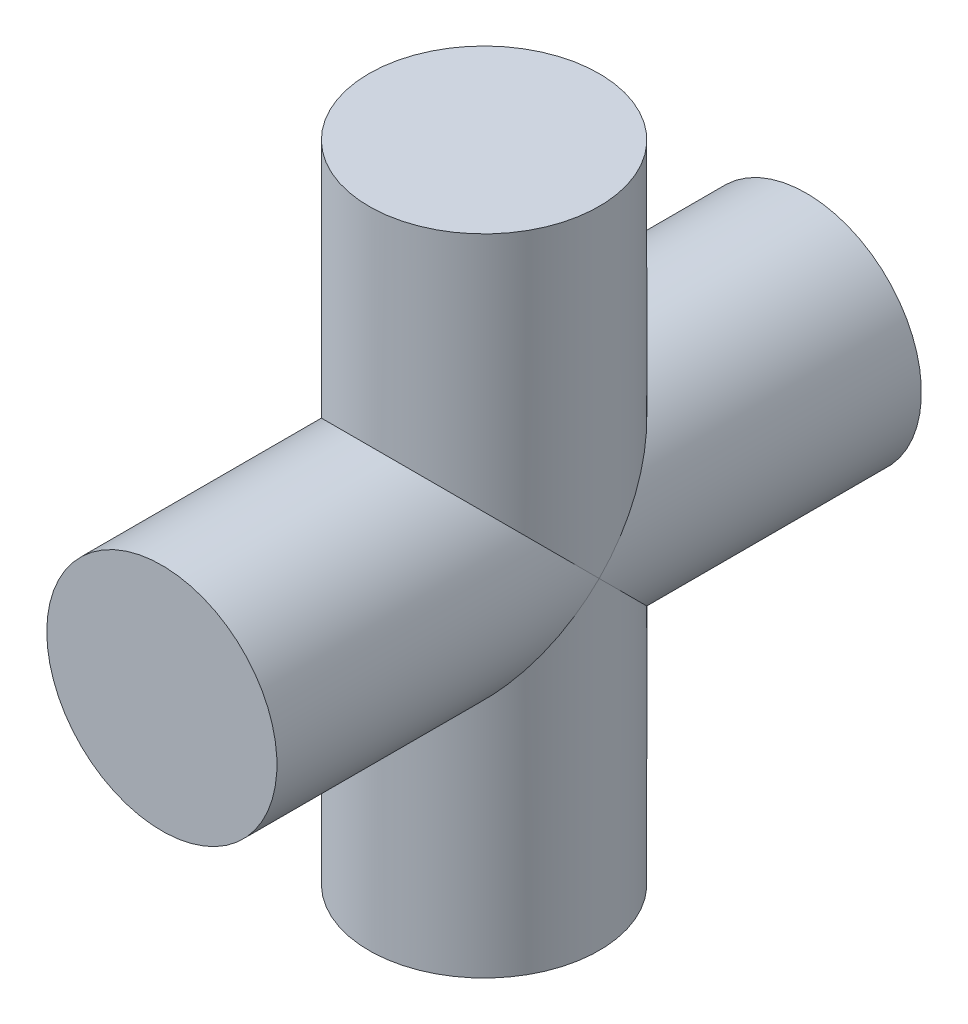
from build123d import *

# Parameters (mm, degrees)
SKETCH1_W = 7.5
SKETCH1_H = 42
SKETCH2_W = 7.5
SKETCH2_H = 42


with BuildPart() as part:
    # Sketch1 → Revolve1 (revolve)
    with BuildSketch(Plane.XY):
        with Locations((-3.75, 0)):
            Rectangle(SKETCH1_W, SKETCH1_H)
    revolve(axis=Axis((0, 21, 0), (0, -1, 0)))

    # Sketch2 → Revolve2 (revolve)
    with BuildSketch(Plane(origin=(0, 0, 0), x_dir=(1, 0, 0), z_dir=(0, 1, 0))):
        with Locations((-3.75, 0)):
            Rectangle(SKETCH2_W, SKETCH2_H)
    revolve(axis=Axis((0, 0, -21), (0, 0, 1)))


solid = part.part
